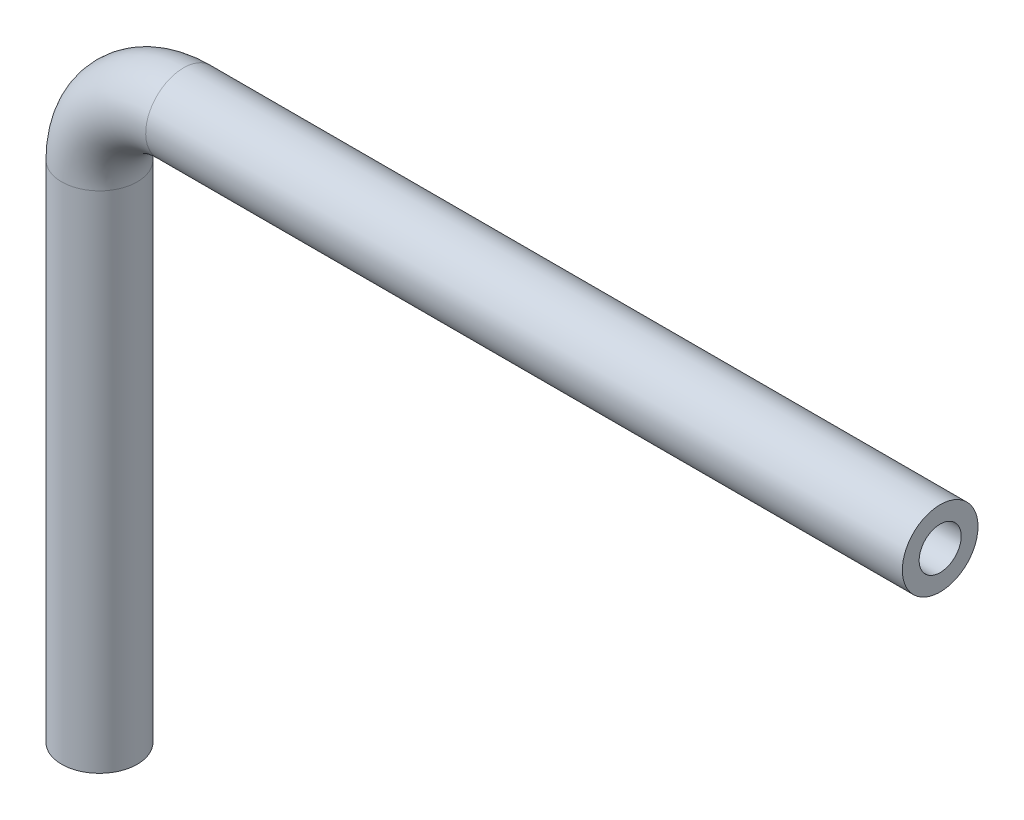
from build123d import *

# Parameters (mm, degrees)
SKETCH1_R           = 0.45
SKETCH1_R_2         = 0.25
REVOLVE1_ANGLE      = 90
SKETCH6_R           = 0.45
BOSS_EXTRUDE1_DEPTH = 6
SKETCH11_R          = 0.45
BOSS_EXTRUDE2_DEPTH = 9
SKETCH17_W          = 9
SKETCH17_H          = 0.25
SKETCH19_W          = 0.25
SKETCH19_H          = 6


with BuildPart() as part:
    # Sketch1 → Revolve1 (revolve)
    with BuildSketch(Plane(origin=(1, 0, 0), x_dir=(0, 0, -1), z_dir=(1, 0, 0))):
        with Locations((0, 7)):
            Circle(SKETCH1_R)
        with Locations((0, 7)):
            Circle(SKETCH1_R_2, mode=Mode.SUBTRACT)
    revolve(axis=Axis((1, 6, 0.4), (0, 0, 1)), revolution_arc=REVOLVE1_ANGLE)

    # Sketch6 → Boss-Extrude1 (add)
    with BuildSketch(Plane(origin=(0, 6, 0), x_dir=(-1, 0, 0), z_dir=(0, -1, 0))):
        Circle(SKETCH6_R)
    extrude(amount=BOSS_EXTRUDE1_DEPTH)

    # Sketch11 → Boss-Extrude2 (add)
    with BuildSketch(Plane(origin=(1, 0, 0), x_dir=(0, 0, -1), z_dir=(1, 0, 0))):
        with Locations((0, 7)):
            Circle(SKETCH11_R)
    extrude(amount=BOSS_EXTRUDE2_DEPTH)

    # Sketch17 → Cut-Revolve1 (revolve, cut)
    with BuildSketch(Plane(origin=(0, 0, 0), x_dir=(-1, 0, 0), z_dir=(0, 0, -1))):
        with Locations((-5.5, 7.125)):
            Rectangle(SKETCH17_W, SKETCH17_H)
    revolve(axis=Axis((10, 7, 0), (-1, 0, 0)), mode=Mode.SUBTRACT)

    # Sketch19 → Cut-Revolve2 (revolve, cut)
    with BuildSketch(Plane.XY):
        with Locations((0.125, 3)):
            Rectangle(SKETCH19_W, SKETCH19_H)
    revolve(axis=Axis((0, 6, 0), (0, -1, 0)), mode=Mode.SUBTRACT)


solid = part.part
